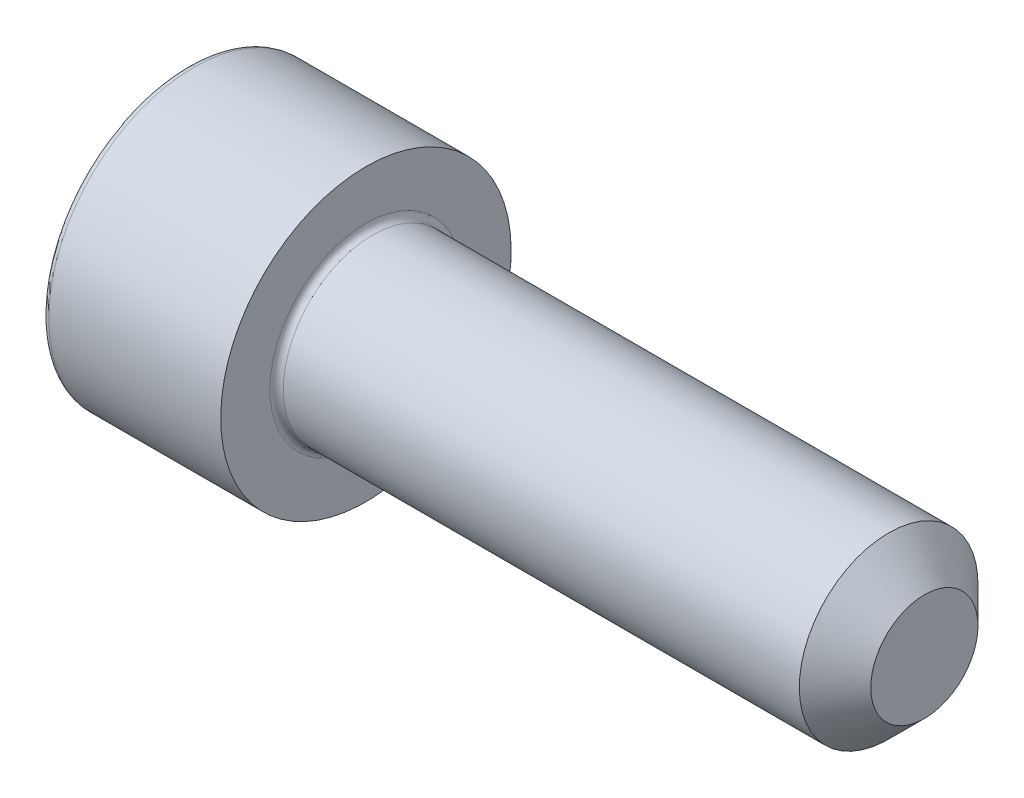
from build123d import *

# Parameters (mm, degrees)
CUT_EXTRUDE_1_DEPTH = 2.5
FILLET_1_R          = 0.3
CHAMFER_1_SIZE      = 1.6


with BuildPart() as part:
    # Эскиз1 → Повернуть1 (revolve)
    with BuildSketch(Plane.XY):
        Polygon((0, 0), (0, 6.5), (8, 6.5), (8, 4), (33, 4), (33, 0), align=None)
    revolve(axis=Axis((33, 0, 0), (-1, 0, 0)))

    # Эскиз2 → Вырез-Вытянуть1 (cut)
    with BuildSketch(Plane.ZY):
        Polygon((-1.732050808, 3), (-3.464101615, 0), (-1.732050808, -3), (1.732050808, -3), (3.464101615, 0), (1.732050808, 3), align=None)
    extrude(amount=-CUT_EXTRUDE_1_DEPTH, mode=Mode.SUBTRACT)

    # Скругление1
    fillet_1_edges = [part.edges().sort_by_distance(p)[0] for p in [
        (8, -4, 0),
        (0, -6.5, 0),
    ]]
    fillet(fillet_1_edges, radius=FILLET_1_R)

    # Фаска1
    chamfer_1_edges = [part.edges().sort_by_distance(p)[0] for p in [
        (33, -4, 0),
    ]]
    chamfer(chamfer_1_edges, length=CHAMFER_1_SIZE)


solid = part.part
